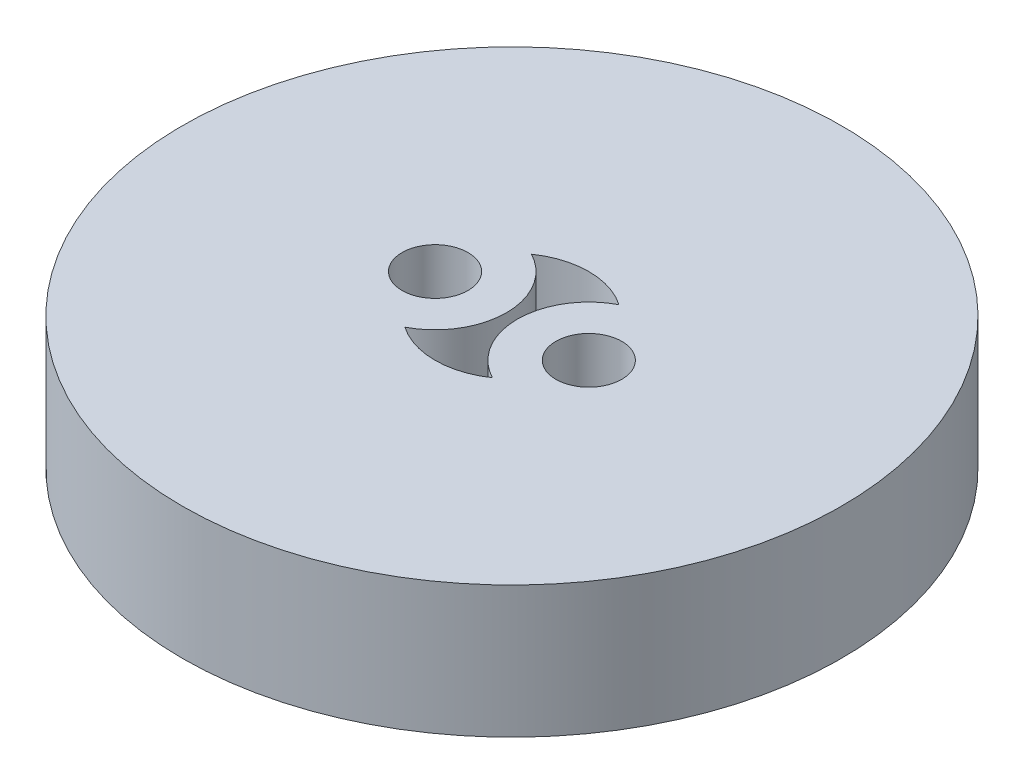
from build123d import *

# Parameters (mm, degrees)
ESQUISSE1_R        = 15
ESQUISSE1_R_2      = 1.5
BOSS_EXTRU_1_DEPTH = 6


with BuildPart() as part:
    # Esquisse1 → Boss.-Extru.1 (new body)
    with BuildSketch(Plane(origin=(0, 0, 0), x_dir=(1, 0, 0), z_dir=(0, 1, 0))):
        Circle(ESQUISSE1_R)
        with Locations((-3.5, 0)):
            Circle(ESQUISSE1_R_2, mode=Mode.SUBTRACT)
        with Locations((3.5, 0)):
            Circle(ESQUISSE1_R_2, mode=Mode.SUBTRACT)
        with BuildLine():
            ThreePointArc((1.991071429, 2.878477821), (0.25, 0), (1.991071429, -2.878477821))
            ThreePointArc((1.991071429, -2.878477821), (0, -3.5), (-1.991071429, -2.878477821))
            ThreePointArc((-1.991071429, -2.878477821), (-0.25, 0), (-1.991071429, 2.878477821))
            ThreePointArc((-1.991071429, 2.878477821), (0, 3.5), (1.991071429, 2.878477821))
        make_face(mode=Mode.SUBTRACT)
    extrude(amount=BOSS_EXTRU_1_DEPTH)


solid = part.part
